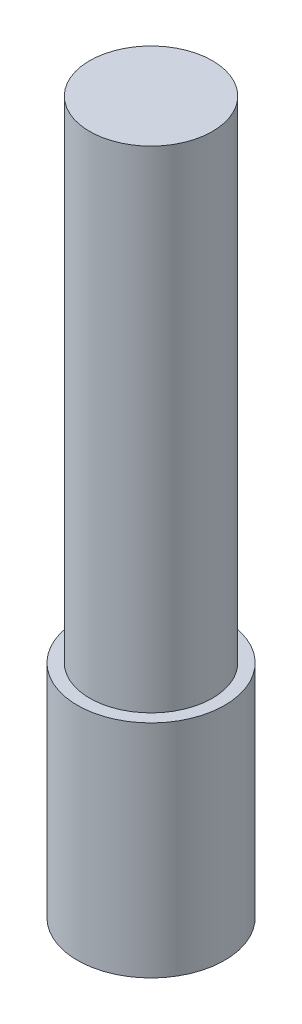
from build123d import *


with BuildPart() as part:
    # Sketch1 → Revolve1 (revolve)
    with BuildSketch(Plane.XY):
        Polygon((3, 0), (3, 9), (2.5, 9), (2.5, 29), (0, 29), (0, 0), align=None)
    revolve(axis=Axis((0, 0, 0), (0, 1, 0)))


solid = part.part
